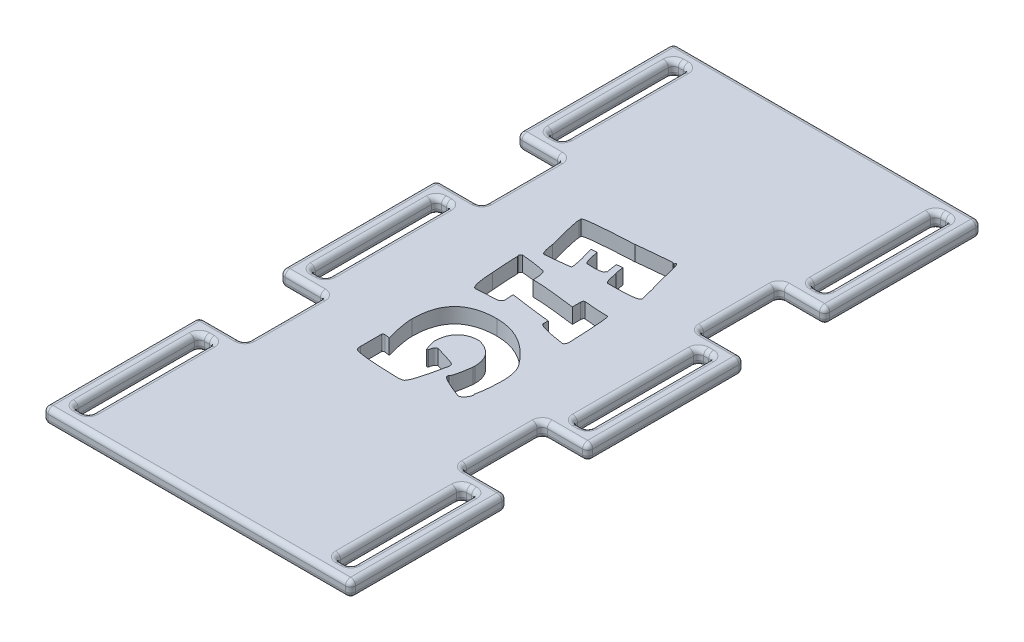
from build123d import *

# Parameters (mm, degrees)
SKETCH1_W           = 43
SKETCH1_H           = 125
BOSS_EXTRUDE2_DEPTH = 3
SKETCH3_W           = 9
SKETCH3_H           = 31
SKETCH3_W_2         = 3
SKETCH3_H_2         = 25
BOSS_EXTRUDE3_DEPTH = 3
FILLET1_R           = 1
CUT_EXTRUDE1_DEPTH  = 3


with BuildPart() as part:
    # Sketch1 → Boss-Extrude2 (new body)
    with BuildSketch(Plane(origin=(0, 0, 0), x_dir=(1, 0, 0), z_dir=(0, 1, 0))):
        with Locations((21.5, 62.5)):
            Rectangle(SKETCH1_W, SKETCH1_H)
    extrude(amount=BOSS_EXTRUDE2_DEPTH)

    # Sketch3 → Boss-Extrude3 (add)
    with BuildSketch(Plane(origin=(0, 0, 0), x_dir=(1, 0, 0), z_dir=(0, 1, 0))):
        with Locations((-4.5, 15.5)):
            Rectangle(SKETCH3_W, SKETCH3_H)
        with Locations((-4.5, 15.5)):
            Rectangle(SKETCH3_W_2, SKETCH3_H_2, mode=Mode.SUBTRACT)
        with Locations((47.5, 15.5)):
            Rectangle(SKETCH3_W, SKETCH3_H)
        with Locations((47.5, 15.5)):
            Rectangle(SKETCH3_W_2, SKETCH3_H_2, mode=Mode.SUBTRACT)
        with Locations((-4.5, 109.5)):
            Rectangle(SKETCH3_W, SKETCH3_H)
        with Locations((-4.5, 109.5)):
            Rectangle(SKETCH3_W_2, SKETCH3_H_2, mode=Mode.SUBTRACT)
        with Locations((47.5, 109.5)):
            Rectangle(SKETCH3_W, SKETCH3_H)
        with Locations((47.5, 109.5)):
            Rectangle(SKETCH3_W_2, SKETCH3_H_2, mode=Mode.SUBTRACT)
        with Locations((-4.5, 62.5)):
            Rectangle(SKETCH3_W, SKETCH3_H)
        with Locations((-4.5, 62.5)):
            Rectangle(SKETCH3_W_2, SKETCH3_H_2, mode=Mode.SUBTRACT)
        with Locations((47.5, 62.5)):
            Rectangle(SKETCH3_W, SKETCH3_H)
        with Locations((47.5, 62.5)):
            Rectangle(SKETCH3_W_2, SKETCH3_H_2, mode=Mode.SUBTRACT)
    extrude(amount=BOSS_EXTRUDE3_DEPTH)

    # Fillet1
    fillet1_edges = [part.edges().sort_by_distance(p)[0] for p in [
        (43, 0, -86),
        (43, 3, -86),
        (47.5, 3, -47),
        (52, 3, -62.5),
        (47.5, 3, -78),
        (46, 0, -62.5),
        (47.5, 0, -50),
        (49, 0, -62.5),
        (47.5, 0, -75),
        (43, 1.5, -78),
        (47.5, 0, -47),
        (43, 1.5, -47),
        (52, 0, -62.5),
        (52, 1.5, -47),
        (47.5, 0, -78),
        (52, 1.5, -78),
        (46, 3, -62.5),
        (46, 1.5, -50),
        (47.5, 3, -50),
        (49, 1.5, -50),
        (49, 3, -62.5),
        (49, 1.5, -75),
        (47.5, 3, -75),
        (46, 1.5, -75),
        (21.5, 3, 0),
        (0, 0, -39),
        (0, 3, -39),
        (-4.5, 3, -31),
        (-9, 3, -15.5),
        (-6, 0, -15.5),
        (-4.5, 0, -3),
        (-3, 0, -15.5),
        (-4.5, 0, -28),
        (-4.5, 0, -31),
        (0, 1.5, -31),
        (-9, 0, -15.5),
        (-9, 1.5, -31),
        (-9, 1.5, 0),
        (-6, 3, -15.5),
        (-6, 1.5, -3),
        (-4.5, 3, -3),
        (-3, 1.5, -3),
        (-3, 3, -15.5),
        (-3, 1.5, -28),
        (-4.5, 3, -28),
        (-6, 1.5, -28),
        (43, 0, -39),
        (43, 3, -39),
        (52, 3, -15.5),
        (47.5, 3, -31),
        (47.5, 0, -28),
        (46, 0, -15.5),
        (47.5, 0, -3),
        (49, 0, -15.5),
        (43, 1.5, -31),
        (52, 0, -15.5),
        (52, 1.5, 0),
        (47.5, 0, -31),
        (52, 1.5, -31),
        (46, 3, -15.5),
        (46, 1.5, -3),
        (47.5, 3, -3),
        (49, 1.5, -3),
        (49, 3, -15.5),
        (49, 1.5, -28),
        (47.5, 3, -28),
        (46, 1.5, -28),
        (21.5, 0, 0),
        (21.5, 0, -125),
        (-9, 3, -109.5),
        (-4.5, 3, -94),
        (-4.5, 0, -122),
        (-6, 0, -109.5),
        (-4.5, 0, -97),
        (-3, 0, -109.5),
        (0, 1.5, -94),
        (-9, 0, -109.5),
        (-9, 1.5, -125),
        (-4.5, 0, -94),
        (-9, 1.5, -94),
        (-6, 3, -109.5),
        (-6, 1.5, -97),
        (-4.5, 3, -97),
        (-3, 1.5, -97),
        (-3, 3, -109.5),
        (-3, 1.5, -122),
        (-4.5, 3, -122),
        (-6, 1.5, -122),
        (21.5, 3, -125),
        (47.5, 3, -94),
        (52, 3, -109.5),
        (46, 0, -109.5),
        (47.5, 0, -97),
        (49, 0, -109.5),
        (47.5, 0, -122),
        (47.5, 0, -94),
        (43, 1.5, -94),
        (52, 0, -109.5),
        (52, 1.5, -94),
        (52, 1.5, -125),
        (46, 3, -109.5),
        (46, 1.5, -97),
        (47.5, 3, -97),
        (49, 1.5, -97),
        (49, 3, -109.5),
        (49, 1.5, -122),
        (47.5, 3, -122),
        (46, 1.5, -122),
        (0, 0, -86),
        (0, 3, -86),
        (-4.5, 3, -78),
        (-9, 3, -62.5),
        (-4.5, 3, -47),
        (-4.5, 0, -75),
        (-6, 0, -62.5),
        (-4.5, 0, -50),
        (-3, 0, -62.5),
        (0, 1.5, -47),
        (-4.5, 0, -78),
        (0, 1.5, -78),
        (-9, 0, -62.5),
        (-9, 1.5, -78),
        (-4.5, 0, -47),
        (-9, 1.5, -47),
        (-6, 3, -62.5),
        (-6, 1.5, -50),
        (-4.5, 3, -50),
        (-3, 1.5, -50),
        (-3, 3, -62.5),
        (-3, 1.5, -75),
        (-4.5, 3, -75),
        (-6, 1.5, -75),
    ]]
    fillet(fillet1_edges, radius=FILLET1_R)

    # Sketch4 → Cut-Extrude1 (cut)
    with BuildSketch(Plane(origin=(0, 3, 0), x_dir=(1, 0, 0), z_dir=(0, 1, 0))):
        with BuildLine():
            add(Edge.make_bspline(
                [(32.138544705, 77.718655327), (32.135839292, 77.686025612), (32.130209018, 77.618119456), (32.063045068, 77.529704897), (31.967654985, 77.448448492), (31.833518255, 77.378238998), (31.666295678, 77.30557591), (31.459751172, 77.248435775), (31.218152832, 77.187979219), (30.938748333, 77.1421292), (30.622227458, 77.095781818), (30.269751584, 77.054894138), (29.880004606, 77.022042655), (29.453020648, 76.998574461), (28.989083231, 76.978346466), (28.486659557, 76.960597442), (27.948320342, 76.953995797), (27.576633873, 76.951712048), (27.385292589, 76.950536392)],
                knots=[0, 0, 0, 0, 9.6408e-05, 0.000200636, 0.000320681, 0.000472303, 0.000651789, 0.000867364, 0.001113764, 0.001398921, 0.001716046, 0.002073591, 0.002463183, 0.002889261, 0.00335637, 0.003856333, 0.004397384, 0.004971423, 0.004971423, 0.004971423, 0.004971423], degree=3))
            Line((27.385292589, 76.950536392), (26.047278961, 76.950536392))
            add(Edge.make_bspline(
                [(26.047278961, 76.950536392), (26.00560623, 76.96107161), (25.909170929, 76.985451266), (25.787918939, 77.120903832), (25.68160415, 77.325966311), (25.573785583, 77.60764917), (25.46129261, 77.963743409), (25.362632143, 78.401283695), (25.258289411, 78.915823444), (25.19920228, 79.287654523), (25.16765889, 79.486154811)],
                knots=[0, 0, 0, 0, 0.000126681, 0.000293153, 0.000520585, 0.000822729, 0.001194973, 0.00164071, 0.002167142, 0.002770017, 0.002770017, 0.002770017, 0.002770017], degree=3))
            add(Edge.make_bspline(
                [(25.16765889, 79.486154811), (25.155815677, 79.493712391), (25.119073533, 79.517158874), (25.092535423, 79.608103144), (25.048839557, 79.735097394), (25.010613539, 79.919386032), (24.970142306, 80.15189803), (24.923805119, 80.436780165), (24.88059292, 80.774506227), (24.849666551, 81.016882316), (24.833155483, 81.14628283)],
                knots=[0, 0, 0, 0, 4.1297e-05, 0.000128118, 0.00026657, 0.000452909, 0.000687829, 0.000976375, 0.001318041, 0.001709381, 0.001709381, 0.001709381, 0.001709381], degree=3))
            Line((24.833155483, 81.14628283), (23.664458395, 81.034781695))
            add(Edge.make_bspline(
                [(23.664458395, 81.034781695), (23.689026771, 80.817069031), (23.735603368, 80.404330513), (23.825828386, 79.822844803), (23.906926215, 79.308981909), (23.978191012, 78.993056909), (24.011350817, 78.846055698)],
                knots=[0, 0, 0, 0, 0.000657189, 0.001245895, 0.001765266, 0.002217234, 0.002217234, 0.002217234, 0.002217234], degree=3))
            Line((24.011350817, 78.846055698), (23.817256247, 78.846055698))
            add(Edge.make_bspline(
                [(23.817256247, 78.846055698), (23.819132497, 78.784500915), (23.822956083, 78.659059152), (23.674759926, 78.497668071), (23.442484727, 78.389893062), (23.115152331, 78.308612423), (22.690321433, 78.253736007), (22.16555992, 78.234169609), (21.540035974, 78.238980575), (21.090231704, 78.263147607), (20.848022302, 78.276161005)],
                knots=[0, 0, 0, 0, 0.000178343, 0.000363442, 0.000610981, 0.000944566, 0.001369742, 0.001894795, 0.002518389, 0.003245962, 0.003245962, 0.003245962, 0.003245962], degree=3))
            Line((20.848022302, 78.276161005), (20.62502003, 78.276161005))
            add(Edge.make_bspline(
                [(20.62502003, 78.276161005), (20.587227958, 78.288404732), (20.490473856, 78.319750744), (20.382646552, 78.485707869), (20.271840522, 78.72122615), (20.148267192, 79.049714313), (20.027599747, 79.469666365), (19.901780687, 79.983083014), (19.764184265, 80.588030153), (19.681909582, 81.024821775), (19.638028496, 81.257783966)],
                knots=[0, 0, 0, 0, 0.000116586, 0.000298479, 0.000560737, 0.000909713, 0.00134482, 0.00187266, 0.00249483, 0.003205925, 0.003205925, 0.003205925, 0.003205925], degree=3))
            Line((19.638028496, 81.257783966), (18.494109438, 81.14628283))
            add(Edge.make_bspline(
                [(18.494109438, 81.14628283), (18.590277037, 80.834153236), (18.772911056, 80.241381002), (19.013854222, 79.394944392), (19.225758648, 78.64260419), (19.385119816, 77.979455613), (19.508312686, 77.408372089), (19.587324654, 76.929107184), (19.633348264, 76.539738963), (19.62508487, 76.310501899), (19.621509809, 76.21132516)],
                knots=[0, 0, 0, 0, 0.000979786, 0.001860733, 0.00264018, 0.003324286, 0.003906629, 0.004392054, 0.004782018, 0.005079383, 0.005079383, 0.005079383, 0.005079383], degree=3))
            add(Edge.make_bspline(
                [(19.621509809, 76.21132516), (19.614844944, 76.205450475), (19.593682337, 76.186796889), (19.533480996, 76.17050896), (19.441134493, 76.144758621), (19.306273464, 76.122316545), (19.135720899, 76.093881647), (18.92685294, 76.059053376), (18.681229521, 76.02894797), (18.398154532, 75.989207713), (18.075617713, 75.954015929), (17.714938369, 75.912987391), (17.317431511, 75.866013451), (16.882107378, 75.822264574), (16.408869853, 75.771155449), (15.896481677, 75.723293446), (15.347285665, 75.669106451), (14.968746758, 75.631791576), (14.773275244, 75.612522764)],
                knots=[0, 0, 0, 0, 2.6443e-05, 8.3962e-05, 0.000182124, 0.000316576, 0.000492415, 0.000701525, 0.000951498, 0.001234764, 0.001559016, 0.001924766, 0.002323808, 0.002759797, 0.003237288, 0.003751759, 0.004303623, 0.00489288, 0.00489288, 0.00489288, 0.00489288], degree=3))
            add(Edge.make_bspline(
                [(14.773275244, 75.612522764), (14.725705279, 75.622206448), (14.619572857, 75.643811526), (14.490914265, 75.787117423), (14.36687617, 75.987574956), (14.264447274, 76.274759198), (14.147559021, 76.631482526), (14.057140437, 77.073166133), (13.95873133, 77.591367232), (13.908281134, 77.964731487), (13.881266159, 78.164659869)],
                knots=[0, 0, 0, 0, 0.000142399, 0.000317703, 0.000551459, 0.000853603, 0.001225846, 0.0016787, 0.002203575, 0.002808625, 0.002808625, 0.002808625, 0.002808625], degree=3))
            add(Edge.make_bspline(
                [(13.881266159, 78.164659869), (13.819788089, 78.397422382), (13.700409326, 78.849403085), (13.518499391, 79.506895015), (13.361120668, 80.130792505), (13.206296561, 80.716325654), (13.066990175, 81.265850373), (12.935958919, 81.778266859), (12.828504307, 82.256183792), (12.722157926, 82.695639557), (12.632397312, 83.099241187), (12.5528623, 83.466587037), (12.488620876, 83.797616391), (12.42793346, 84.089773009), (12.386642041, 84.346266882), (12.359674911, 84.565513493), (12.333931505, 84.748150212), (12.333039394, 84.85879062), (12.332639274, 84.908413741)],
                knots=[0, 0, 0, 0, 0.000722232, 0.001402438, 0.002046482, 0.002652475, 0.003219384, 0.003747223, 0.004239071, 0.004688826, 0.005103606, 0.005479429, 0.005816345, 0.006115198, 0.006374546, 0.00659532, 0.006778195, 0.00692692, 0.00692692, 0.00692692, 0.00692692], degree=3))
            Line((12.332639274, 84.908413741), (12.332639274, 85.354418284))
            add(Edge.make_bspline(
                [(12.332639274, 85.354418284), (12.343242763, 85.378135902), (12.372473576, 85.443518656), (12.50971922, 85.496094444), (12.694826865, 85.564439165), (12.965750165, 85.620075554), (13.306700413, 85.688871951), (13.728026022, 85.746992282), (14.223778934, 85.80751654), (14.792979333, 85.877233217), (15.439543982, 85.929823211), (16.161921452, 85.993917279), (16.96163234, 86.056233053), (17.837539015, 86.110790332), (18.788360163, 86.176156514), (19.815532065, 86.231327407), (20.919486185, 86.290010212), (21.680821581, 86.326611619), (22.074534794, 86.34553949)],
                knots=[0, 0, 0, 0, 7.5811e-05, 0.000208989, 0.000410117, 0.000681578, 0.001030651, 0.001456408, 0.001955825, 0.002529538, 0.003176355, 0.003901698, 0.004705245, 0.005582643, 0.006534485, 0.007564397, 0.008668534, 0.009851035, 0.009851035, 0.009851035, 0.009851035], degree=3))
            add(Edge.make_bspline(
                [(22.074534794, 86.34553949), (22.083981391, 86.351549291), (22.1173262, 86.37276282), (22.206785003, 86.37805353), (22.340260058, 86.409131336), (22.531730607, 86.429797983), (22.773583024, 86.459818212), (23.069772204, 86.491843923), (23.419300703, 86.529779949), (23.821381923, 86.569977239), (24.276733786, 86.61704438), (24.78498883, 86.660661226), (25.346573933, 86.710741162), (25.961912121, 86.764250506), (26.629556376, 86.821902214), (27.350856612, 86.884022009), (28.12430748, 86.950852302), (28.658578111, 86.992884578), (28.933919473, 87.014546303)],
                knots=[0, 0, 0, 0, 3.3294e-05, 0.000117524, 0.000260102, 0.000447582, 0.000692941, 0.000992107, 0.001340985, 0.001747795, 0.002204324, 0.002714301, 0.003278118, 0.003895777, 0.004567277, 0.005288505, 0.00606769, 0.006896263, 0.006896263, 0.006896263, 0.006896263], degree=3))
            add(Edge.make_bspline(
                [(28.933919473, 87.014546303), (28.994547373, 86.982833291), (29.100327357, 86.927502298), (29.218136263, 86.910361641), (29.26842288, 86.903045168)],
                knots=[0, 0, 0, 0, 0.000203363, 0.000354815, 0.000354815, 0.000354815, 0.000354815], degree=3))
            add(Edge.make_bspline(
                [(29.26842288, 86.903045168), (29.269589556, 86.936781458), (29.271707597, 86.998027975), (29.316020227, 87.074672231), (29.387281175, 87.123212939), (29.443744483, 87.125039412), (29.474906464, 87.126047439)],
                knots=[0, 0, 0, 0, 9.9883e-05, 0.000181333, 0.000255782, 0.000347476, 0.000347476, 0.000347476, 0.000347476], degree=3))
            add(Edge.make_bspline(
                [(29.474906464, 87.126047439), (29.49050417, 87.121463777), (29.52879527, 87.110211258), (29.58379933, 87.05909065), (29.632126921, 86.972909616), (29.697426261, 86.86282695), (29.755187366, 86.71662452), (29.82367262, 86.541324134), (29.891110523, 86.332340514), (29.96649447, 86.091755954), (30.043605078, 85.820126198), (30.127617905, 85.51626532), (30.212538324, 85.179887605), (30.304318955, 84.811186131), (30.397916283, 84.411648674), (30.499792256, 83.980311896), (30.595000006, 83.514947479), (30.665232386, 83.194513636), (30.701418956, 83.029413122)],
                knots=[0, 0, 0, 0, 4.8337e-05, 0.000118662, 0.00021717, 0.000344723, 0.000501976, 0.000687582, 0.000909588, 0.001160378, 0.001444006, 0.001756581, 0.002106143, 0.002484746, 0.002896431, 0.003337205, 0.003814267, 0.004321326, 0.004321326, 0.004321326, 0.004321326], degree=3))
            add(Edge.make_bspline(
                [(30.701418956, 83.029413122), (30.73353718, 82.931820897), (30.809225231, 82.701840387), (30.926414453, 82.301781487), (31.071486042, 81.796738238), (31.241213476, 81.1859881), (31.428804505, 80.467785636), (31.644680528, 79.644900361), (31.883229359, 78.716844413), (32.050516637, 78.062812692), (32.138544705, 77.718655327)],
                knots=[0, 0, 0, 0, 0.000308207, 0.000726305, 0.001250448, 0.001884658, 0.002627908, 0.003477306, 0.004436857, 0.005502568, 0.005502568, 0.005502568, 0.005502568], degree=3))
        make_face()
        with BuildLine():
            Line((32.332639274, 63.235896706), (32.332639274, 63.041802137))
            add(Edge.make_bspline(
                [(32.332639274, 63.041802137), (32.328614497, 62.940755215), (32.321094969, 62.751968321), (32.247257565, 62.491513859), (32.117501576, 62.27684242), (31.990658787, 62.180779961), (31.927931449, 62.133274365)],
                knots=[0, 0, 0, 0, 0.000302483, 0.000565131, 0.000804581, 0.001038846, 0.001038846, 0.001038846, 0.001038846], degree=3))
            add(Edge.make_bspline(
                [(31.927931449, 62.133274365), (31.711801751, 62.166241521), (31.293198618, 62.230092786), (30.685721755, 62.32392626), (30.119913236, 62.41891788), (29.595334804, 62.513563513), (29.112046585, 62.608302838), (28.671296257, 62.702479925), (28.273168255, 62.796915859), (27.918758765, 62.893461953), (27.602748255, 62.980686722), (27.33140988, 63.077495979), (27.098606905, 63.166595987), (26.907897075, 63.254941652), (26.75954324, 63.347337033), (26.65171649, 63.434705394), (26.577324784, 63.525774901), (26.567889136, 63.592815209), (26.563487922, 63.624085845)],
                knots=[0, 0, 0, 0, 0.00065589, 0.001270338, 0.00184402, 0.00237702, 0.002869439, 0.003321407, 0.003729075, 0.004096708, 0.004423449, 0.004712083, 0.00496055, 0.005171123, 0.005341844, 0.005482496, 0.00558907, 0.00568224, 0.00568224, 0.00568224, 0.00568224], degree=3))
            Line((26.563487922, 63.624085845), (26.563487922, 64.627596066))
            Line((26.563487922, 64.627596066), (26.464375801, 64.627596066))
            add(Edge.make_bspline(
                [(26.464375801, 64.627596066), (26.435452215, 64.628740242), (26.358200653, 64.631796205), (26.216680395, 64.646570082), (26.020650212, 64.659994134), (25.772267932, 64.693698763), (25.468570541, 64.72194832), (25.112897129, 64.771863061), (24.702241831, 64.819150023), (24.238374334, 64.877278272), (23.719441113, 64.943584419), (23.148474521, 65.018918326), (22.521469078, 65.094931997), (21.843577286, 65.188793112), (21.109115355, 65.280805571), (20.323835162, 65.390929696), (19.482387478, 65.501035555), (18.904300741, 65.578626832), (18.605610573, 65.618717272)],
                knots=[0, 0, 0, 0, 8.6821e-05, 0.00023189, 0.000426686, 0.000676147, 0.000983523, 0.001341568, 0.001753398, 0.002223619, 0.00274404, 0.003322857, 0.003951355, 0.004638781, 0.005375878, 0.00617192, 0.007017625, 0.007921731, 0.007921731, 0.007921731, 0.007921731], degree=3))
            Line((18.605610573, 65.618717272), (18.605610573, 65.519605151))
            add(Edge.make_bspline(
                [(18.605610573, 65.519605151), (18.606006134, 65.425963519), (18.606885333, 65.217829188), (18.632223541, 64.876655434), (18.659155849, 64.473092297), (18.686090753, 64.184290236), (18.700593022, 64.028793671)],
                knots=[0, 0, 0, 0, 0.000280848, 0.000624232, 0.001025852, 0.001494329, 0.001494329, 0.001494329, 0.001494329], degree=3))
            add(Edge.make_bspline(
                [(18.700593022, 64.028793671), (18.697501351, 63.957889985), (18.691662099, 63.823973927), (18.623700282, 63.638829518), (18.526481717, 63.476532745), (18.376535283, 63.350610866), (18.192184536, 63.248963539), (17.962665855, 63.189083249), (17.699179333, 63.139799898), (17.508799124, 63.137828373), (17.408005783, 63.136784586)],
                knots=[0, 0, 0, 0, 0.000211623, 0.000399693, 0.000585299, 0.000772551, 0.00097953, 0.001212115, 0.001480289, 0.00178201, 0.00178201, 0.00178201, 0.00178201], degree=3))
            add(Edge.make_bspline(
                [(17.408005783, 63.136784586), (17.337807354, 63.131198992), (17.174045675, 63.118168699), (16.894556559, 63.09815349), (16.547820762, 63.07238891), (16.133419676, 63.048073628), (15.651488038, 63.024509453), (15.102249297, 62.995435776), (14.485685066, 62.961176138), (14.051977535, 62.940955531), (13.823450755, 62.930301001)],
                knots=[0, 0, 0, 0, 0.00021126, 0.000492836, 0.000840612, 0.001254322, 0.001738128, 0.002288135, 0.002904342, 0.003590663, 0.003590663, 0.003590663, 0.003590663], degree=3))
            add(Edge.make_bspline(
                [(13.823450755, 62.930301001), (13.786841254, 62.933082152), (13.712246161, 62.938748994), (13.609539957, 63.001923139), (13.508338356, 63.088297898), (13.420322922, 63.217329121), (13.331501362, 63.374937619), (13.257793312, 63.571762276), (13.175981388, 63.798527), (13.10974103, 64.063491834), (13.042065167, 64.360357583), (12.986143042, 64.692985754), (12.932369101, 65.06058939), (12.883537625, 65.464117401), (12.838610847, 65.901960909), (12.796082424, 66.373993272), (12.764621712, 66.882230464), (12.746647979, 67.233402987), (12.7373471, 67.415124458)],
                knots=[0, 0, 0, 0, 0.000108635, 0.000221353, 0.00035305, 0.000506683, 0.000685979, 0.000895333, 0.001135636, 0.0014091, 0.00171369, 0.002049084, 0.002420525, 0.002828256, 0.003268352, 0.003740942, 0.004249965, 0.004795847, 0.004795847, 0.004795847, 0.004795847], degree=3))
            add(Edge.make_bspline(
                [(12.7373471, 67.415124458), (12.713705748, 67.733092621), (12.668473802, 68.341446925), (12.607570028, 69.211497892), (12.550786125, 69.997244872), (12.514003985, 70.698342315), (12.470409992, 71.314513871), (12.45506169, 71.84630448), (12.433692296, 72.293487605), (12.432352659, 72.563428874), (12.431751395, 72.684585535)],
                knots=[0, 0, 0, 0, 0.000956534, 0.001830094, 0.002616566, 0.003319824, 0.003936266, 0.004469394, 0.004915704, 0.005279139, 0.005279139, 0.005279139, 0.005279139], degree=3))
            Line((12.431751395, 72.684585535), (12.332639274, 72.878680105))
            add(Edge.make_bspline(
                [(12.332639274, 72.878680105), (12.363974165, 72.948488184), (12.420226003, 73.073806402), (12.518246388, 73.229969075), (12.62026969, 73.34050161), (12.701530753, 73.369651879), (12.7373471, 73.382500051)],
                knots=[0, 0, 0, 0, 0.000229039, 0.000411166, 0.000554282, 0.000667075, 0.000667075, 0.000667075, 0.000667075], degree=3))
            add(Edge.make_bspline(
                [(12.7373471, 73.382500051), (13.149284481, 73.347211239), (13.965140259, 73.277320564), (15.171152927, 73.116585946), (16.349496511, 72.926099478), (17.120855977, 72.764595011), (17.502988232, 72.684585535)],
                knots=[0, 0, 0, 0, 0.001240174, 0.002456206, 0.00364906, 0.004820169, 0.004820169, 0.004820169, 0.004820169], degree=3))
            add(Edge.make_bspline(
                [(17.502988232, 72.684585535), (17.545126707, 72.633727331), (17.633786103, 72.526721614), (17.727088995, 72.327701044), (17.815017012, 72.103289389), (17.890574275, 71.845471152), (17.940935486, 71.553047571), (17.976838315, 71.228872941), (18.002902227, 70.873447848), (18.005469107, 70.625307587), (18.006808178, 70.495859539)],
                knots=[0, 0, 0, 0, 0.000197405, 0.000415341, 0.000654612, 0.000921224, 0.001219305, 0.001543557, 0.001899572, 0.002287849, 0.002287849, 0.002287849, 0.002287849], degree=3))
            Line((18.006808178, 70.495859539), (18.006808178, 70.202652849))
            add(Edge.make_bspline(
                [(18.006808178, 70.202652849), (18.231227762, 70.199898482), (18.717489693, 70.193930449), (19.503625238, 70.152917551), (20.404241044, 70.092171866), (21.416924427, 69.997382784), (22.543569579, 69.888631367), (23.781722254, 69.74365931), (25.13570168, 69.58640727), (26.074978045, 69.462046091), (26.563487922, 69.397366869)],
                knots=[0, 0, 0, 0, 0.00067325, 0.001458768, 0.002361165, 0.003381119, 0.00450991, 0.005756742, 0.007120816, 0.008599106, 0.008599106, 0.008599106, 0.008599106], degree=3))
            Line((26.563487922, 69.397366869), (26.563487922, 70.999679485))
            add(Edge.make_bspline(
                [(26.563487922, 70.999679485), (26.564764963, 71.077494621), (26.567049029, 71.216671687), (26.625460773, 71.396782589), (26.717250222, 71.535255815), (26.811079489, 71.569463022), (26.856694612, 71.586092866)],
                knots=[0, 0, 0, 0, 0.000231851, 0.000414679, 0.000565001, 0.000707221, 0.000707221, 0.000707221, 0.000707221], degree=3))
            add(Edge.make_bspline(
                [(26.856694612, 71.586092866), (27.104414177, 71.562016688), (27.584477645, 71.515358712), (28.285374114, 71.458417434), (28.944739147, 71.408583961), (29.562837845, 71.367236501), (30.139628538, 71.334072498), (30.67367811, 71.307854554), (31.168012552, 71.295761807), (31.483298911, 71.293819181), (31.634724759, 71.292886175)],
                knots=[0, 0, 0, 0, 0.000746649, 0.001446954, 0.002109557, 0.002730383, 0.003305357, 0.003842786, 0.004334373, 0.004788656, 0.004788656, 0.004788656, 0.004788656], degree=3))
            add(Edge.make_bspline(
                [(31.634724759, 71.292886175), (31.652482041, 71.283069304), (31.70109426, 71.256194701), (31.743318792, 71.146883866), (31.791305176, 70.992017444), (31.832977447, 70.767100198), (31.884257519, 70.486128692), (31.926857829, 70.139620351), (31.97407899, 69.731131896), (32.010985384, 69.258240157), (32.060271588, 68.723303908), (32.098709225, 68.125510358), (32.140226774, 67.464789009), (32.183024445, 66.740844567), (32.216647004, 65.953137196), (32.261328789, 65.102706838), (32.296291496, 64.189879419), (32.320261501, 63.560763378), (32.332639274, 63.235896706)],
                knots=[0, 0, 0, 0, 5.9559e-05, 0.000163048, 0.000331557, 0.000555094, 0.000844318, 0.001190078, 0.001601432, 0.002078136, 0.002612797, 0.003213022, 0.003875059, 0.00459893, 0.005388572, 0.006240287, 0.007153701, 0.008129012, 0.008129012, 0.008129012, 0.008129012], degree=3))
        make_face()
        with BuildLine():
            add(Edge.make_bspline(
                [(32.332639274, 49.83924174), (32.325952821, 49.373807706), (32.31292283, 48.466809584), (32.221632996, 47.140688449), (32.070170764, 45.883697321), (31.910733578, 45.075551628), (31.832949, 44.681281798)],
                knots=[0, 0, 0, 0, 0.00139622, 0.002720834, 0.003986024, 0.00519128, 0.00519128, 0.00519128, 0.00519128], degree=3))
            Line((31.832949, 44.681281798), (31.956839151, 44.433501497))
            add(Edge.make_bspline(
                [(31.956839151, 44.433501497), (31.91094038, 44.304561316), (31.824132193, 44.060697197), (31.665831446, 43.727847425), (31.498969136, 43.444440068), (31.315840191, 43.213291588), (31.12053188, 43.031096119), (30.910668275, 42.90029653), (30.687056043, 42.815248921), (30.531452629, 42.806604214), (30.453638655, 42.802281179)],
                knots=[0, 0, 0, 0, 0.000410357, 0.000776107, 0.00110402, 0.001394891, 0.001657961, 0.00190091, 0.002133422, 0.002366008, 0.002366008, 0.002366008, 0.002366008], degree=3))
            add(Edge.make_bspline(
                [(30.453638655, 42.802281179), (30.275960273, 42.870843782), (29.931106225, 43.003916196), (29.431252093, 43.201809924), (28.96673918, 43.392266684), (28.53393934, 43.568099471), (28.140682203, 43.743060675), (27.777817252, 43.902165131), (27.453677232, 44.060949316), (27.159214986, 44.204337643), (26.899417318, 44.339135944), (26.675539718, 44.468255602), (26.484751451, 44.585434267), (26.332610701, 44.698577705), (26.2077792, 44.796215787), (26.121851409, 44.891388489), (26.060235114, 44.976431529), (26.051158691, 45.035824136), (26.047278961, 45.061211594)],
                knots=[0, 0, 0, 0, 0.000571344, 0.001108916, 0.001612753, 0.002077501, 0.002510231, 0.00290396, 0.003265984, 0.003592881, 0.003886582, 0.004143718, 0.004368283, 0.004557438, 0.004712891, 0.004841509, 0.004943504, 0.005019652, 0.005019652, 0.005019652, 0.005019652], degree=3))
            Line((26.047278961, 45.061211594), (26.047278961, 45.437011717))
            add(Edge.make_bspline(
                [(26.047278961, 45.437011717), (26.091219281, 45.452853521), (26.205517216, 45.494061355), (26.321074633, 45.705282433), (26.439904193, 46.000773773), (26.566524578, 46.417565314), (26.686585273, 46.948574631), (26.807855436, 47.598310701), (26.937293335, 48.364512419), (27.011279591, 48.916671664), (27.050789182, 49.211531643)],
                knots=[0, 0, 0, 0, 0.000136716, 0.000355628, 0.000677742, 0.001110098, 0.00165302, 0.002313109, 0.003091823, 0.003984214, 0.003984214, 0.003984214, 0.003984214], degree=3))
            Line((27.050789182, 49.211531643), (27.050789182, 49.587331767))
            add(Edge.make_bspline(
                [(27.050789182, 49.587331767), (27.046898719, 49.736063586), (27.039247185, 50.028580621), (27.000469776, 50.457136967), (26.924178037, 50.86545316), (26.821845387, 51.253785542), (26.68962162, 51.624966634), (26.524241931, 51.973601544), (26.332782712, 52.30516998), (26.109356136, 52.614441772), (25.856505555, 52.903465774), (25.576731339, 53.17479442), (25.268054073, 53.428273749), (24.92213253, 53.651723687), (24.553712246, 53.866275143), (24.153085091, 54.053126815), (23.724449923, 54.224849459), (23.425595738, 54.320418587), (23.272139584, 54.369491585)],
                knots=[0, 0, 0, 0, 0.00044631, 0.000877777, 0.001289255, 0.001690938, 0.002081515, 0.002469462, 0.002846983, 0.003228637, 0.003612074, 0.003997574, 0.004396809, 0.004807996, 0.005231605, 0.005674944, 0.00613276, 0.00661595, 0.00661595, 0.00661595, 0.00661595], degree=3))
            Line((23.272139584, 54.369491585), (23.148249433, 54.369491585))
            add(Edge.make_bspline(
                [(23.148249433, 54.369491585), (22.89149592, 54.363162616), (22.397652821, 54.350989394), (21.693846386, 54.213813276), (21.055645437, 54.00476536), (20.494981782, 53.690715172), (19.99634635, 53.302161928), (19.587660695, 52.809371422), (19.23447206, 52.242462922), (19.075868608, 51.815356953), (18.993799712, 51.594352209)],
                knots=[0, 0, 0, 0, 0.000769228, 0.001479544, 0.00214297, 0.00277512, 0.00339814, 0.004027925, 0.004685892, 0.005391437, 0.005391437, 0.005391437, 0.005391437], degree=3))
            add(Edge.make_bspline(
                [(18.993799712, 51.594352209), (18.957468585, 51.415496911), (18.892165258, 51.094013737), (18.812247373, 50.665007292), (18.762403707, 50.342726389), (18.750686795, 50.162817636), (18.746019411, 50.091151713)],
                knots=[0, 0, 0, 0, 0.000547489, 0.000984084, 0.001309385, 0.001524763, 0.001524763, 0.001524763, 0.001524763], degree=3))
            add(Edge.make_bspline(
                [(18.746019411, 50.091151713), (18.747547326, 50.020863393), (18.750794419, 49.871488158), (18.782376998, 49.635601953), (18.832080845, 49.375065058), (18.904223269, 49.090632053), (18.990936969, 48.779009648), (19.097534203, 48.442620524), (19.227411303, 48.082959895), (19.321062284, 47.836214614), (19.369599836, 47.708331148)],
                knots=[0, 0, 0, 0, 0.000210775, 0.000447935, 0.000712782, 0.00100625, 0.001327888, 0.001683135, 0.002064544, 0.002474901, 0.002474901, 0.002474901, 0.002474901], degree=3))
            Line((19.369599836, 47.708331148), (19.621509809, 47.708331148))
            add(Edge.make_bspline(
                [(19.621509809, 47.708331148), (19.634916164, 47.806366336), (19.660225222, 47.991441114), (19.721889922, 48.247097289), (19.79602946, 48.464411187), (19.879794408, 48.645456364), (19.985107759, 48.786596104), (20.105733271, 48.889183359), (20.243919196, 48.951289702), (20.340862645, 48.959580678), (20.389628744, 48.963751342)],
                knots=[0, 0, 0, 0, 0.000296705, 0.000560131, 0.000787376, 0.000984997, 0.001155967, 0.001311421, 0.001455664, 0.00160167, 0.00160167, 0.00160167, 0.00160167], degree=3))
            add(Edge.make_bspline(
                [(20.389628744, 48.963751342), (20.552201084, 48.918808538), (20.866774278, 48.831845397), (21.320160893, 48.698016584), (21.743749888, 48.576016196), (22.134042521, 48.452316902), (22.498022771, 48.351540133), (22.82385413, 48.238241217), (23.12311786, 48.146459579), (23.389579899, 48.055072475), (23.625000694, 47.972592506), (23.829607859, 47.898979068), (24.001050715, 47.828489505), (24.14442699, 47.768212721), (24.252715871, 47.709048695), (24.33607672, 47.667019129), (24.385119696, 47.622782415), (24.398708762, 47.591669501), (24.403669628, 47.580311325)],
                knots=[0, 0, 0, 0, 0.000505999, 0.000979094, 0.001418162, 0.001828353, 0.002207294, 0.002550752, 0.002862891, 0.003146278, 0.003395739, 0.003611314, 0.00379843, 0.003951896, 0.004077495, 0.00416816, 0.004232402, 0.004269339, 0.004269339, 0.004269339, 0.004269339], degree=3))
            add(Edge.make_bspline(
                [(24.403669628, 47.580311325), (24.422809416, 47.542278535), (24.465114262, 47.458214318), (24.504095493, 47.309913109), (24.522286316, 47.133412648), (24.525717506, 47.007706352), (24.527559778, 46.940212213)],
                knots=[0, 0, 0, 0, 0.000127486, 0.000281783, 0.000456454, 0.000658976, 0.000658976, 0.000658976, 0.000658976], degree=3))
            add(Edge.make_bspline(
                [(24.527559778, 46.940212213), (24.469878175, 46.660744062), (24.358441911, 46.120833852), (24.194335946, 45.336725574), (24.029974745, 44.608559432), (23.866173702, 43.933640892), (23.717611753, 43.311010223), (23.563530018, 42.744407954), (23.41417606, 42.232871268), (23.275428275, 41.771633855), (23.136948068, 41.36494678), (22.998749914, 41.013698769), (22.875444631, 40.713718961), (22.74532616, 40.472351191), (22.624160263, 40.279915478), (22.506866754, 40.141842101), (22.390519457, 40.049211209), (22.306915631, 40.03407391), (22.268629363, 40.027141802)],
                knots=[0, 0, 0, 0, 0.000856078, 0.001653875, 0.002403259, 0.003095395, 0.003737423, 0.004323458, 0.004856682, 0.005336097, 0.005768374, 0.006144922, 0.006468647, 0.006740234, 0.006967028, 0.007148451, 0.007284793, 0.007399981, 0.007399981, 0.007399981, 0.007399981], degree=3))
            Line((22.268629363, 40.027141802), (21.645048938, 39.903251651))
            add(Edge.make_bspline(
                [(21.645048938, 39.903251651), (21.291254136, 39.913688459), (20.60562014, 39.933914392), (19.61046651, 39.972697205), (18.681168946, 40.008381116), (17.817991346, 40.049066734), (17.021143344, 40.096360609), (16.289714958, 40.13808987), (15.62514733, 40.194045292), (15.024952095, 40.247553056), (14.490404395, 40.299128195), (14.022197968, 40.356618463), (13.621115253, 40.417559069), (13.286173665, 40.481894609), (13.014938848, 40.551280311), (12.812182367, 40.620407571), (12.65986724, 40.681477362), (12.60634251, 40.750598511), (12.584549248, 40.77874205)],
                knots=[0, 0, 0, 0, 0.00106184, 0.002057784, 0.002987704, 0.003851792, 0.004650112, 0.005382474, 0.006049516, 0.00665072, 0.007190255, 0.007660475, 0.008065815, 0.008406782, 0.008684239, 0.008902331, 0.00905563, 0.009160917, 0.009160917, 0.009160917, 0.009160917], degree=3))
            add(Edge.make_bspline(
                [(12.584549248, 40.77874205), (12.543643151, 40.792618743), (12.442288117, 40.827001704), (12.380087524, 41.034518328), (12.339161236, 41.305641811), (12.335028796, 41.529132173), (12.332639274, 41.65836212)],
                knots=[0, 0, 0, 0, 0.000123752, 0.000306627, 0.00058702, 0.000971434, 0.000971434, 0.000971434, 0.000971434], degree=3))
            Line((12.332639274, 41.65836212), (12.332639274, 45.812811841))
            add(Edge.make_bspline(
                [(12.332639274, 45.812811841), (12.33680682, 45.851582123), (12.344815914, 45.926089967), (12.428352253, 46.014949923), (12.556201428, 46.057618428), (12.653046861, 46.062137212), (12.708439398, 46.064721815)],
                knots=[0, 0, 0, 0, 0.000114221, 0.000219507, 0.000343741, 0.000509752, 0.000509752, 0.000509752, 0.000509752], degree=3))
            add(Edge.make_bspline(
                [(12.708439398, 46.064721815), (12.742880526, 46.062235638), (12.845113866, 46.054855796), (13.046924835, 46.026157176), (13.347840109, 45.992796406), (13.579937609, 45.957039655), (13.711949619, 45.936701992)],
                knots=[0, 0, 0, 0, 0.000103572, 0.000307437, 0.000611185, 0.001011827, 0.001011827, 0.001011827, 0.001011827], degree=3))
            add(Edge.make_bspline(
                [(13.711949619, 45.936701992), (13.632187156, 46.237840093), (13.478475847, 46.818167345), (13.277104079, 47.662719867), (13.101549815, 48.445415331), (12.962050214, 49.168781276), (12.848051794, 49.829190858), (12.768465815, 50.429709776), (12.720715366, 50.969999203), (12.712358163, 51.310703066), (12.708439398, 51.470462058)],
                knots=[0, 0, 0, 0, 0.000934529, 0.001800944, 0.002604523, 0.003340729, 0.004010818, 0.00461474, 0.005157631, 0.005636957, 0.005636957, 0.005636957, 0.005636957], degree=3))
            add(Edge.make_bspline(
                [(12.708439398, 51.470462058), (12.714411707, 51.810728546), (12.726020613, 52.472134737), (12.826052915, 53.43041192), (12.988450232, 54.323563612), (13.221594488, 55.149449411), (13.510110339, 55.914358813), (13.878273652, 56.609688225), (14.308231568, 57.242082227), (14.806234889, 57.806850951), (15.371217197, 58.304551294), (16.002003346, 58.733418225), (16.697332089, 59.101580476), (17.462241681, 59.390096629), (18.288127425, 59.623240798), (19.181279133, 59.78563814), (20.139556311, 59.885670436), (20.800962503, 59.897279343), (21.141228992, 59.903251651)],
                knots=[0, 0, 0, 0, 0.001020564, 0.00198376, 0.002886875, 0.003740599, 0.004555067, 0.005334613, 0.00609519, 0.006844199, 0.007587379, 0.008347957, 0.009127503, 0.00994197, 0.010795694, 0.011698809, 0.012662006, 0.013682569, 0.013682569, 0.013682569, 0.013682569], degree=3))
            add(Edge.make_bspline(
                [(21.141228992, 59.903251651), (21.380876306, 59.897797617), (21.856927279, 59.88696337), (22.566535305, 59.821104062), (23.264192771, 59.704043495), (23.952327571, 59.544824743), (24.626216913, 59.329894855), (25.293379809, 59.080825395), (25.946079501, 58.776962295), (26.588052389, 58.428315767), (27.220301697, 58.036299268), (27.840597833, 57.59573647), (28.453461414, 57.113085796), (29.051347299, 56.578794081), (29.638272175, 55.998474601), (30.21648688, 55.375081723), (30.783422779, 54.704702701), (31.145193615, 54.233344496), (31.329129054, 53.993691461)],
                knots=[0, 0, 0, 0, 0.00071899, 0.001428248, 0.002135677, 0.002839868, 0.003545184, 0.004256183, 0.004974948, 0.005703001, 0.006446732, 0.007205243, 0.007984352, 0.008785827, 0.009609321, 0.010459683, 0.011335845, 0.012242061, 0.012242061, 0.012242061, 0.012242061], degree=3))
            add(Edge.make_bspline(
                [(31.329129054, 53.993691461), (31.410549627, 53.860370601), (31.576489676, 53.588654632), (31.773463356, 53.143995307), (31.94919474, 52.67318432), (32.088584809, 52.168449112), (32.200309064, 51.632053623), (32.277335624, 51.062106924), (32.322690925, 50.460811323), (32.329267079, 50.049935371), (32.332639274, 49.83924174)],
                knots=[0, 0, 0, 0, 0.000468185, 0.00095419, 0.001455907, 0.001974949, 0.002523263, 0.003098534, 0.003699057, 0.004331113, 0.004331113, 0.004331113, 0.004331113], degree=3))
        make_face()
    extrude(amount=-CUT_EXTRUDE1_DEPTH, mode=Mode.SUBTRACT)


solid = part.part
